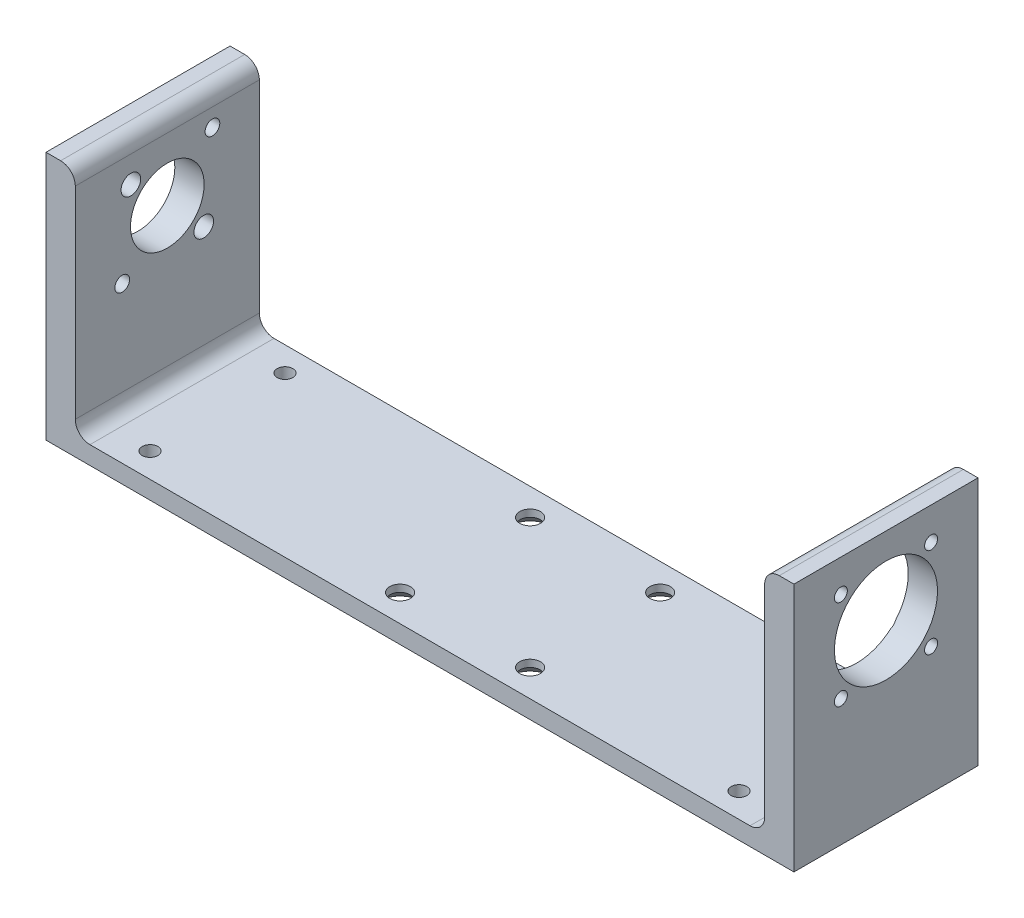
from build123d import *

# Parameters (mm, degrees)
BOSS_EXTRUDE1_DEPTH                             = 37.5
FILLET1_R                                       = 5.969
SKETCH2_R                                       = 21
CUT_EXTRUDE1_DEPTH                              = 21
CIRPATTERN1_COUNT                               = 4
SKETCH5_R                                       = 15
CUT_EXTRUDE2_DEPTH                              = 21
CSK_FOR_M8_FLAT_HEAD_MACHINE_SCREW1_D           = 8.4
CSK_FOR_M8_FLAT_HEAD_MACHINE_SCREW1_DEPTH       = 12.7
CSK_FOR_M8_FLAT_HEAD_MACHINE_SCREW1_CSINK_D     = 17.3
CSK_FOR_M8_FLAT_HEAD_MACHINE_SCREW1_CSINK_ANGLE = 90
CSK_FOR_M8_FLAT_HEAD_MACHINE_SCREW1_TIP         = 2.5236146
M6_CLEARANCE_HOLE1_D                            = 6.4
M6_CLEARANCE_HOLE1_DEPTH                        = 12.7
M6_CLEARANCE_HOLE1_TIP                          = 1.922753981
SKETCH13_R                                      = 3
SKETCH13_R_2                                    = 4
CUT_EXTRUDE3_DEPTH                              = 11.938


with BuildPart() as part:
    # Sketch1 → Boss-Extrude1 (new body, symmetric)
    with BuildSketch(Plane.XY):
        Polygon((-140.462, 101.6), (-152.4, 101.6), (-152.4, 0), (152.4, 0), (152.4, 101.6), (140.462, 101.6), (140.462, 7.366), (-140.462, 7.366), align=None)
    extrude(amount=BOSS_EXTRUDE1_DEPTH, both=True)

    # Fillet1
    fillet1_edges = [part.edges().sort_by_distance(p)[0] for p in [
        (-140.462, 7.366, 0),
        (140.462, 7.366, 0),
        (140.462, 101.6, 0),
        (-140.462, 101.6, 0),
    ]]
    fillet(fillet1_edges, radius=FILLET1_R)

    # Sketch2 → Cut-Extrude1 (cut)
    with BuildSketch(Plane(origin=(152.4, 0, 0), x_dir=(0, 0, -1), z_dir=(1, 0, 0))):
        with Locations((0, 70)):
            Circle(SKETCH2_R)
    extrude(amount=-CUT_EXTRUDE1_DEPTH, mode=Mode.SUBTRACT)

    # Sketch4 → CSK for M5 Flat Head Machine Screw1 (revolve, cut)
    with BuildSketch(Plane(origin=(140.462, 88.384776311, 18.384776311), x_dir=(0, 0, 1), z_dir=(0, 1, 0))):
        Polygon((0, 0), (0, 20.59228064), (2.65, 19), (2.65, 2.55), (5.2, 0), align=None)
    csk_for_m5_flat_head_machine_screw1 = revolve(axis=Axis((134.112, 88.384776311, 18.384776311), (1, 0, 0)), mode=Mode.SUBTRACT)

    # CirPattern1: CSK for M5 Flat Head Machine Screw1 ×4 about axis
    cirpattern1_axis = Axis((0, 70, 0), (1, 0, 0))
    for i in range(1, CIRPATTERN1_COUNT):
        add(csk_for_m5_flat_head_machine_screw1.rotate(cirpattern1_axis, i * 360 / CIRPATTERN1_COUNT), mode=Mode.SUBTRACT)

    # Sketch5 → Cut-Extrude2 (cut)
    with BuildSketch(Plane(origin=(-140.462, 0, 0), x_dir=(0, 0, -1), z_dir=(1, 0, 0))):
        with Locations((0, 70)):
            Circle(SKETCH5_R)
    extrude(amount=-CUT_EXTRUDE2_DEPTH, mode=Mode.SUBTRACT)

    # CSK for M8 Flat Head Machine Screw1
    with Locations(Plane(origin=(-19.12664, 0, 26.5), x_dir=(0, 0, -1), z_dir=(0, -1, 0))):
        with Locations((0, 0), (0, 53), (53, 53), (53, 0)):
            CounterSinkHole(CSK_FOR_M8_FLAT_HEAD_MACHINE_SCREW1_D / 2, CSK_FOR_M8_FLAT_HEAD_MACHINE_SCREW1_CSINK_D / 2, depth=CSK_FOR_M8_FLAT_HEAD_MACHINE_SCREW1_DEPTH, counter_sink_angle=CSK_FOR_M8_FLAT_HEAD_MACHINE_SCREW1_CSINK_ANGLE)
            with Locations((0, 0, -(CSK_FOR_M8_FLAT_HEAD_MACHINE_SCREW1_DEPTH + CSK_FOR_M8_FLAT_HEAD_MACHINE_SCREW1_TIP / 2))):  # 118° drill point
                Cone(0, CSK_FOR_M8_FLAT_HEAD_MACHINE_SCREW1_D / 2, CSK_FOR_M8_FLAT_HEAD_MACHINE_SCREW1_TIP, mode=Mode.SUBTRACT)

    # M6 Clearance Hole1
    with Locations(Plane(origin=(-120, 0, 27.5), x_dir=(0, 0, -1), z_dir=(0, -1, 0))):
        with Locations((0, 0), (0, 240), (55, 240), (55, 0)):
            Hole(M6_CLEARANCE_HOLE1_D / 2, depth=M6_CLEARANCE_HOLE1_DEPTH)
            with Locations((0, 0, -(M6_CLEARANCE_HOLE1_DEPTH + M6_CLEARANCE_HOLE1_TIP / 2))):  # 118° drill point
                Cone(0, M6_CLEARANCE_HOLE1_D / 2, M6_CLEARANCE_HOLE1_TIP, mode=Mode.SUBTRACT)

    # Sketch13 → Cut-Extrude3 (cut)
    with BuildSketch(Plane.ZY.offset(152.4)):
        with Locations((-18.384776311, 88.384776311)):
            Circle(SKETCH13_R)
        with Locations((18.384776311, 51.615223689)):
            Circle(SKETCH13_R)
        with Locations((-14.849242405, 55.150757595)):
            Circle(SKETCH13_R_2)
        with Locations((14.849242405, 84.849242405)):
            Circle(SKETCH13_R_2)
    extrude(amount=-CUT_EXTRUDE3_DEPTH, mode=Mode.SUBTRACT)


solid = part.part
